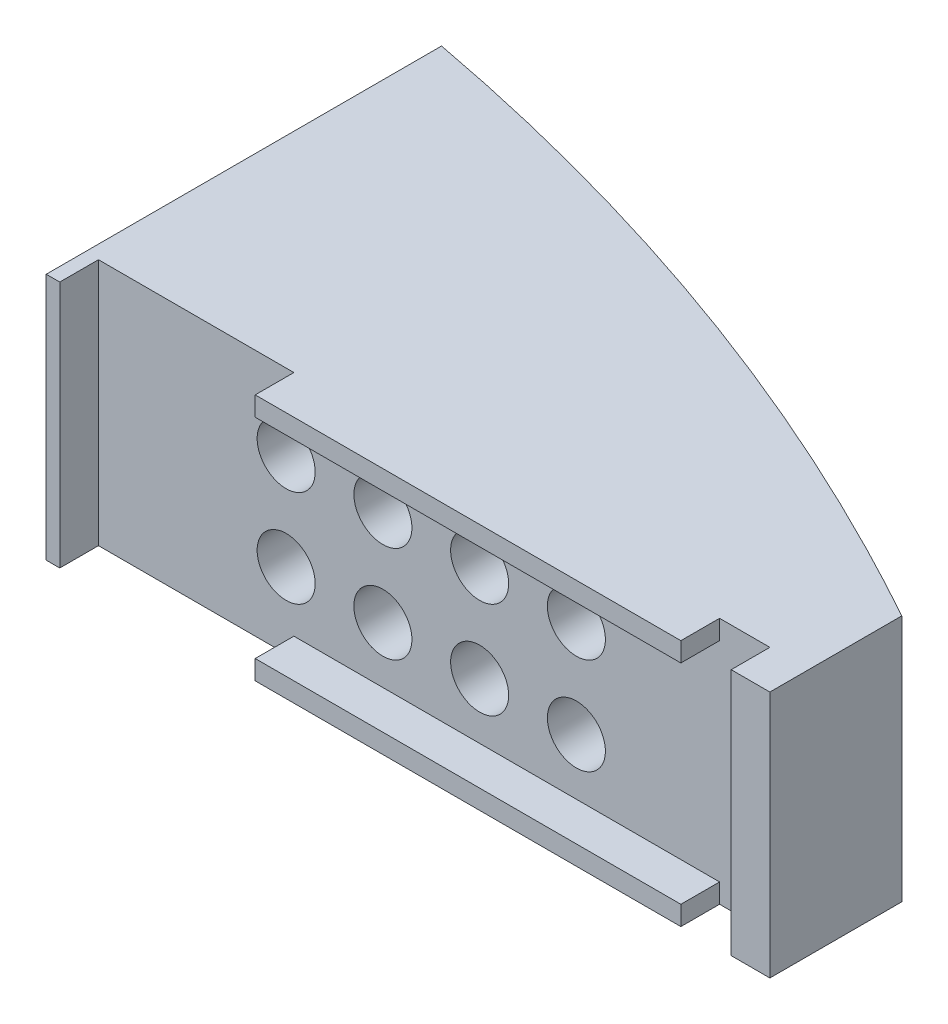
from build123d import *

# Parameters (mm, degrees)
BOSS_EXTRUDE1_DEPTH = 6.4
CUT_EXTRUDE1_REACH  = 17
SKETCH2_R           = 0.75
CUT_EXTRUDE2_REACH  = 8.4
SKETCH9_W           = 0.5
SKETCH9_H           = 6.4
SKETCH9_W_2         = 1
SKETCH9_W_3         = 11
SKETCH9_H_2         = 0.5
BOSS_EXTRUDE2_DEPTH = 1
SKETCH10_W          = 10.242926678
SKETCH10_H          = 6.4
CUT_EXTRUDE7_DEPTH  = 0.15


with BuildPart() as part:
    # Sketch1 → Boss-Extrude1 (new body)
    with BuildSketch(Plane(origin=(0, 0, 0), x_dir=(1, 0, 0), z_dir=(0, 1, 0))):
        Polygon((0, 15), (0, 0), (18.850032676, 0), (18.850032676, 10), align=None)
    extrude(amount=BOSS_EXTRUDE1_DEPTH)

    # Cut-Extrude1: up to this plane
    cut_extrude1_end = Plane(origin=(18.850032676, 6.4, -10), z_dir=(-0.256385401, 0, 0.966574636))
    # Sketch2 → Cut-Extrude1 (cut, up to the surface)
    with BuildSketch(Plane.XY, mode=Mode.PRIVATE) as cut_extrude1_sk1:
        with Locations((12.850032676, 4.45)):
            Circle(SKETCH2_R)
    cut_extrude1_tool1 = split(extrude(cut_extrude1_sk1.sketch, amount=-CUT_EXTRUDE1_REACH, mode=Mode.PRIVATE), bisect_by=cut_extrude1_end, keep=Keep.BOTH, mode=Mode.PRIVATE)
    add(cut_extrude1_tool1.solids().sort_by_distance((12.850033, 4.45, 0))[0], mode=Mode.SUBTRACT)
    # Sketch2 → Cut-Extrude1 (cut, up to the surface)
    with BuildSketch(Plane.XY, mode=Mode.PRIVATE) as cut_extrude1_sk2:
        with Locations((12.850032676, 1.95)):
            Circle(SKETCH2_R)
    cut_extrude1_tool2 = split(extrude(cut_extrude1_sk2.sketch, amount=-CUT_EXTRUDE1_REACH, mode=Mode.PRIVATE), bisect_by=cut_extrude1_end, keep=Keep.BOTH, mode=Mode.PRIVATE)
    add(cut_extrude1_tool2.solids().sort_by_distance((12.850033, 1.95, 0))[0], mode=Mode.SUBTRACT)
    # Sketch2 → Cut-Extrude1 (cut, up to the surface)
    with BuildSketch(Plane.XY, mode=Mode.PRIVATE) as cut_extrude1_sk3:
        with Locations((5.350032676, 1.95)):
            Circle(SKETCH2_R)
    cut_extrude1_tool3 = split(extrude(cut_extrude1_sk3.sketch, amount=-CUT_EXTRUDE1_REACH, mode=Mode.PRIVATE), bisect_by=cut_extrude1_end, keep=Keep.BOTH, mode=Mode.PRIVATE)
    add(cut_extrude1_tool3.solids().sort_by_distance((5.350033, 1.95, 0))[0], mode=Mode.SUBTRACT)
    # Sketch2 → Cut-Extrude1 (cut, up to the surface)
    with BuildSketch(Plane.XY, mode=Mode.PRIVATE) as cut_extrude1_sk4:
        with Locations((5.350032676, 4.45)):
            Circle(SKETCH2_R)
    cut_extrude1_tool4 = split(extrude(cut_extrude1_sk4.sketch, amount=-CUT_EXTRUDE1_REACH, mode=Mode.PRIVATE), bisect_by=cut_extrude1_end, keep=Keep.BOTH, mode=Mode.PRIVATE)
    add(cut_extrude1_tool4.solids().sort_by_distance((5.350033, 4.45, 0))[0], mode=Mode.SUBTRACT)
    # Sketch2 → Cut-Extrude1 (cut, up to the surface)
    with BuildSketch(Plane.XY, mode=Mode.PRIVATE) as cut_extrude1_sk5:
        with Locations((7.850032676, 4.45)):
            Circle(SKETCH2_R)
    cut_extrude1_tool5 = split(extrude(cut_extrude1_sk5.sketch, amount=-CUT_EXTRUDE1_REACH, mode=Mode.PRIVATE), bisect_by=cut_extrude1_end, keep=Keep.BOTH, mode=Mode.PRIVATE)
    add(cut_extrude1_tool5.solids().sort_by_distance((7.850033, 4.45, 0))[0], mode=Mode.SUBTRACT)
    # Sketch2 → Cut-Extrude1 (cut, up to the surface)
    with BuildSketch(Plane.XY, mode=Mode.PRIVATE) as cut_extrude1_sk6:
        with Locations((10.350032676, 4.45)):
            Circle(SKETCH2_R)
    cut_extrude1_tool6 = split(extrude(cut_extrude1_sk6.sketch, amount=-CUT_EXTRUDE1_REACH, mode=Mode.PRIVATE), bisect_by=cut_extrude1_end, keep=Keep.BOTH, mode=Mode.PRIVATE)
    add(cut_extrude1_tool6.solids().sort_by_distance((10.350033, 4.45, 0))[0], mode=Mode.SUBTRACT)
    # Sketch2 → Cut-Extrude1 (cut, up to the surface)
    with BuildSketch(Plane.XY, mode=Mode.PRIVATE) as cut_extrude1_sk7:
        with Locations((7.850032676, 1.95)):
            Circle(SKETCH2_R)
    cut_extrude1_tool7 = split(extrude(cut_extrude1_sk7.sketch, amount=-CUT_EXTRUDE1_REACH, mode=Mode.PRIVATE), bisect_by=cut_extrude1_end, keep=Keep.BOTH, mode=Mode.PRIVATE)
    add(cut_extrude1_tool7.solids().sort_by_distance((7.850033, 1.95, 0))[0], mode=Mode.SUBTRACT)
    # Sketch2 → Cut-Extrude1 (cut, up to the surface)
    with BuildSketch(Plane.XY, mode=Mode.PRIVATE) as cut_extrude1_sk8:
        with Locations((10.350032676, 1.95)):
            Circle(SKETCH2_R)
    cut_extrude1_tool8 = split(extrude(cut_extrude1_sk8.sketch, amount=-CUT_EXTRUDE1_REACH, mode=Mode.PRIVATE), bisect_by=cut_extrude1_end, keep=Keep.BOTH, mode=Mode.PRIVATE)
    add(cut_extrude1_tool8.solids().sort_by_distance((10.350033, 1.95, 0))[0], mode=Mode.SUBTRACT)

    # Sketch3 → Cut-Extrude2 (cut, up to next)
    with BuildSketch(Plane(origin=(0, 6.4, 0), x_dir=(1, 0, 0), z_dir=(0, 1, 0)), mode=Mode.PRIVATE) as cut_extrude2_sk1:
        with BuildLine():
            Line((0, 15), (0, 9.242926678))
            add(Edge.make_bspline(
                [(18.850032676, 2.408422132), (9.827679117, 7.423862257), (0, 9.242926678)],
                knots=[2.52003539, 2.52003539, 2.52003539, 2.823158509, 2.823158509, 2.823158509], degree=2, weights=[1, 0.988536516, 1]))
            Line((18.850032676, 2.408422132), (18.850032676, 10))
            Line((18.850032676, 10), (0, 15))
        make_face()
    cut_extrude2_tool1 = extrude(cut_extrude2_sk1.sketch, amount=-CUT_EXTRUDE2_REACH, mode=Mode.PRIVATE) & part.part
    add(cut_extrude2_tool1.solids().sort_by_distance((9.890162, 6.4, -9.301074))[0], mode=Mode.SUBTRACT)

    # Sketch9 → Boss-Extrude2 (add)
    with BuildSketch(Plane.XY):
        with Locations((0.25, 3.2)):
            Rectangle(SKETCH9_W, SKETCH9_H)
        with Locations((18.350032676, 3.2)):
            Rectangle(SKETCH9_W_2, SKETCH9_H)
        with Locations((11.050032676, 6.15)):
            Rectangle(SKETCH9_W_3, SKETCH9_H_2)
        with Locations((11.050032676, 0.25)):
            Rectangle(SKETCH9_W_3, SKETCH9_H_2)
    extrude(amount=BOSS_EXTRUDE2_DEPTH)

    # Sketch10 → Cut-Extrude7 (cut)
    with BuildSketch(Plane.ZY):
        with Locations((-4.121463339, 3.2)):
            Rectangle(SKETCH10_W, SKETCH10_H)
    extrude(amount=-CUT_EXTRUDE7_DEPTH, mode=Mode.SUBTRACT)


solid = part.part
